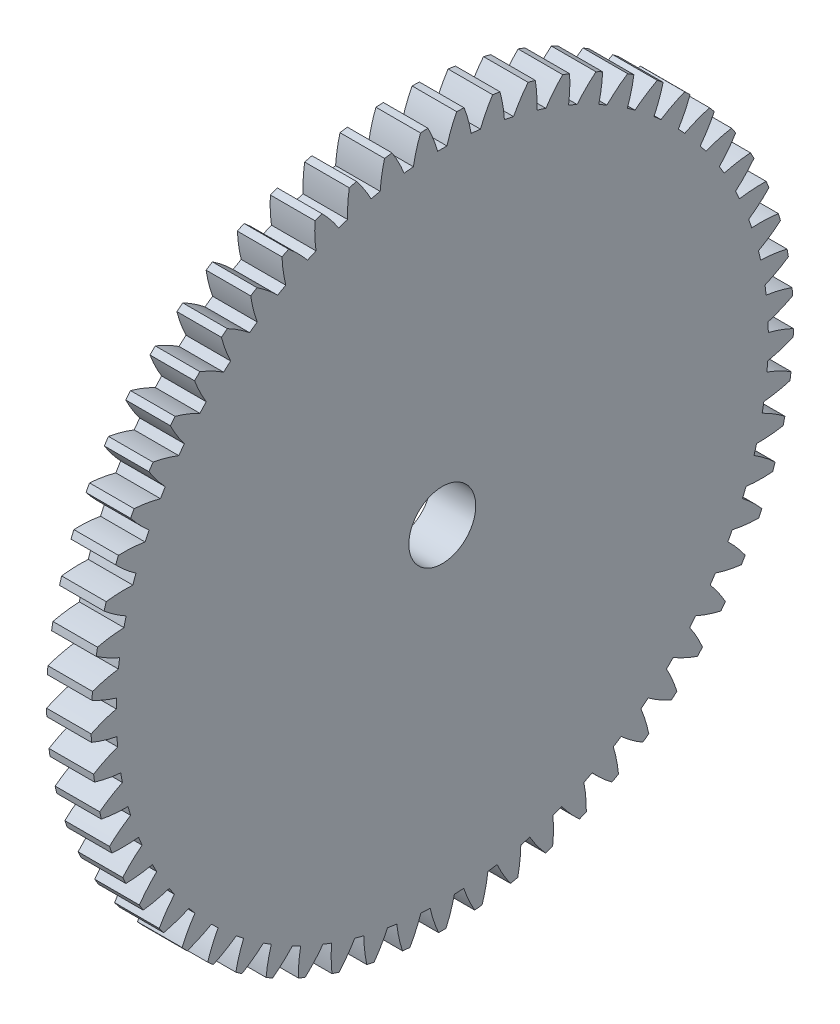
from build123d import *

# Parameters (mm, degrees)
BASPROSKE_W     = 1
BASPROSKE_H     = 7.875
TOOTHCUT_DEPTH  = 12.181737343
TEETHCUTS_COUNT = 61
TEETHCUTS_ANGLE = 354.098360656
BORSKE_R        = 0.75
BORE_DEPTH      = 50.0000508


with BuildPart() as part:
    # BasProSke → Base-Revolve (revolve)
    with BuildSketch(Plane(origin=(0, 0, 0), x_dir=(1, 0, 0), z_dir=(0, 1, 0)), mode=Mode.PRIVATE) as base_revolve_sk:
        with Locations((0.5, 3.9375)):
            Rectangle(BASPROSKE_W, BASPROSKE_H)
    revolve(base_revolve_sk.sketch.rotate(Axis((-10, 0, 0), (1, 0, 0)), 180), axis=Axis((-10, 0, 0), (1, 0, 0)))

    # TooCutSke → ToothCut (cut, through all)
    with BuildSketch(Plane(origin=(0, 0, 0), x_dir=(0, 0, -1), z_dir=(1, 0, 0))):
        with BuildLine():
            ThreePointArc((0.104655197, 7.310750956), (0, 7.3115), (-0.104655197, 7.310750956))
            ThreePointArc((-0.104655197, 7.310750956), (-0.204698451, 7.60794997), (-0.334729025, 7.893305812))
            ThreePointArc((-0.334729025, 7.893305812), (0, 7.9004), (0.334729025, 7.893305812))
            ThreePointArc((0.334729025, 7.893305812), (0.204698451, 7.60794997), (0.104655197, 7.310750956))
        make_face()
    toothcut = extrude(amount=TOOTHCUT_DEPTH, mode=Mode.SUBTRACT)

    # TeethCuts: ToothCut ×61 about axis
    teethcuts_axis = Axis((-10, 0, 0), (1, 0, 0))
    for i in range(1, TEETHCUTS_COUNT):
        add(toothcut.rotate(teethcuts_axis, i * TEETHCUTS_ANGLE / (TEETHCUTS_COUNT - 1)), mode=Mode.SUBTRACT)

    # BorSke → Bore (cut, symmetric)
    with BuildSketch(Plane(origin=(0, 0, 0), x_dir=(0, 0, -1), z_dir=(1, 0, 0))):
        with Locations(Location((0, 0, 0), (0, 0, 180))):
            Circle(BORSKE_R)
    extrude(amount=BORE_DEPTH, both=True, mode=Mode.SUBTRACT)


solid = part.part
